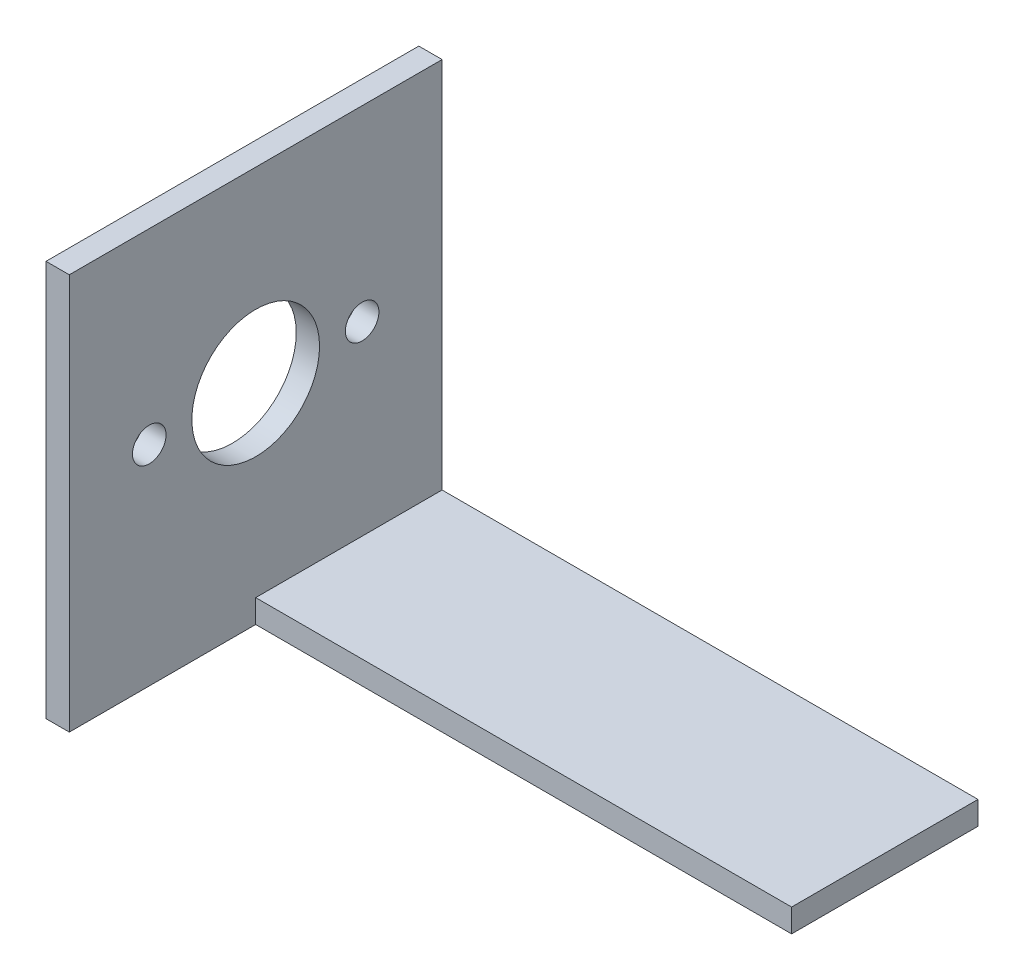
from build123d import *

# Parameters (mm, degrees)
SKETCH1_W           = 76.2
SKETCH1_H           = 50.8
BOSS_EXTRUDE1_DEPTH = 3.175
SKETCH2_W           = 50.8
SKETCH2_H           = 53.975
BOSS_EXTRUDE2_DEPTH = 3.175
SKETCH4_R           = 2.286
SKETCH4_R_2         = 8.6995
CUT_EXTRUDE2_DEPTH  = 3.175
SKETCH6_W           = 73.025
SKETCH6_H           = 25.4
CUT_EXTRUDE3_DEPTH  = 3.175


with BuildPart() as part:
    # Sketch1 → Boss-Extrude1 (new body)
    with BuildSketch(Plane(origin=(0, 0, 0), x_dir=(1, 0, 0), z_dir=(0, 1, 0))):
        with Locations((38.1, 25.4)):
            Rectangle(SKETCH1_W, SKETCH1_H)
    extrude(amount=BOSS_EXTRUDE1_DEPTH)

    # Sketch2 → Boss-Extrude2 (add)
    with BuildSketch(Plane.ZY):
        with Locations((-25.4, 26.9875)):
            Rectangle(SKETCH2_W, SKETCH2_H)
    extrude(amount=-BOSS_EXTRUDE2_DEPTH)

    # Sketch4 → Cut-Extrude2 (cut)
    with BuildSketch(Plane(origin=(3.175, 0, 0), x_dir=(0, 0, -1), z_dir=(1, 0, 0))):
        with Locations((10.8966, 28.4988)):
            Circle(SKETCH4_R)
        with Locations((39.9034, 28.4988)):
            Circle(SKETCH4_R)
        with Locations((25.4, 28.4988)):
            Circle(SKETCH4_R_2)
    extrude(amount=-CUT_EXTRUDE2_DEPTH, mode=Mode.SUBTRACT)

    # Sketch6 → Cut-Extrude3 (cut)
    with BuildSketch(Plane(origin=(0, 3.175, 0), x_dir=(1, 0, 0), z_dir=(0, 1, 0))):
        with Locations((39.6875, 12.7)):
            Rectangle(SKETCH6_W, SKETCH6_H)
    extrude(amount=-CUT_EXTRUDE3_DEPTH, mode=Mode.SUBTRACT)


solid = part.part
